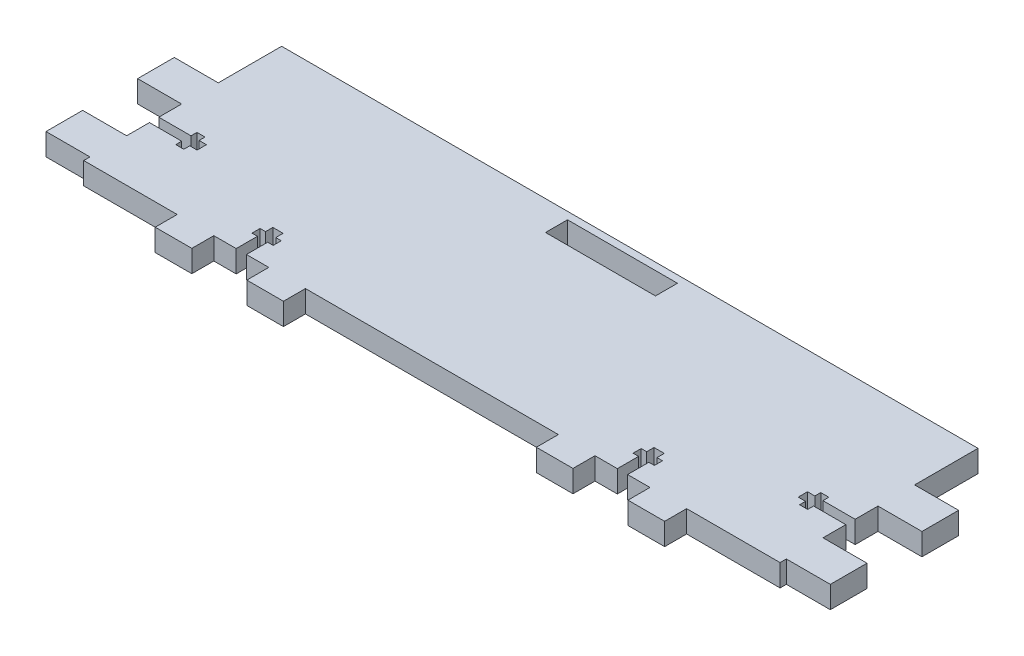
from build123d import *

# Parameters (mm, degrees)
SKETCH_1_W      = 30
SKETCH_1_H      = 6
EXTRUDE_1_DEPTH = 6


with BuildPart() as part:
    # Эскиз1 → Бобышка-Вытянуть1 (new body)
    with BuildSketch(Plane(origin=(0, 0, 0), x_dir=(1, 0, 0), z_dir=(0, 1, 0))):
        Polygon((-95, 23), (-95, 13.709265489), (-107, 13.709265489), (-107, 3.709265489), (-95, 3.709265489), (-95, -2.518957871), (-86.2, -2.518957871), (-86.2, -0.901182203), (-84, -0.901182203), (-84, -2.518957871), (-82, -2.518957871), (-82, -5.062511151), (-84, -5.062511151), (-84, -6.68028682), (-86.2, -6.68028682), (-86.2, -5.062511151), (-95, -5.062511151), (-95, -11.290734511), (-107, -11.290734511), (-107, -21.290734511), (-95, -21.290734511), (-95, -23), (-69.5, -23), (-69.5, -29), (-59.5, -29), (-59.5, -23), (-53.4, -23), (-53.4, -17.2), (-54.9, -17.2), (-54.9, -15), (-53.4, -15), (-53.4, -13), (-50.6, -13), (-50.6, -15), (-49.1, -15), (-49.1, -17.2), (-50.6, -17.2), (-50.6, -23), (-44.5, -23), (-44.5, -29), (-34.5, -29), (-34.5, -23), (34.5, -23), (34.5, -29), (44.5, -29), (44.5, -23), (50.6, -23), (50.6, -17.2), (49.1, -17.2), (49.1, -15), (50.6, -15), (50.6, -13), (53.4, -13), (53.4, -15), (54.9, -15), (54.9, -17.2), (53.4, -17.2), (53.4, -23), (59.5, -23), (59.5, -29), (69.5, -29), (69.5, -23), (95, -23), (95, -21.290734511), (107, -21.290734511), (107, -11.290734511), (95, -11.290734511), (95, -5.062511151), (86.2, -5.062511151), (86.2, -6.68028682), (84, -6.68028682), (84, -5.062511151), (82, -5.062511151), (82, -2.518957871), (84, -2.518957871), (84, -0.901182203), (86.2, -0.901182203), (86.2, -2.518957871), (95, -2.518957871), (95, 3.709265489), (107, 3.709265489), (107, 13.709265489), (95, 13.709265489), (95, 23), (95, 31), (-95, 31), align=None)
        with Locations((0, 26)):
            Rectangle(SKETCH_1_W, SKETCH_1_H, mode=Mode.SUBTRACT)
    extrude(amount=EXTRUDE_1_DEPTH)


solid = part.part
